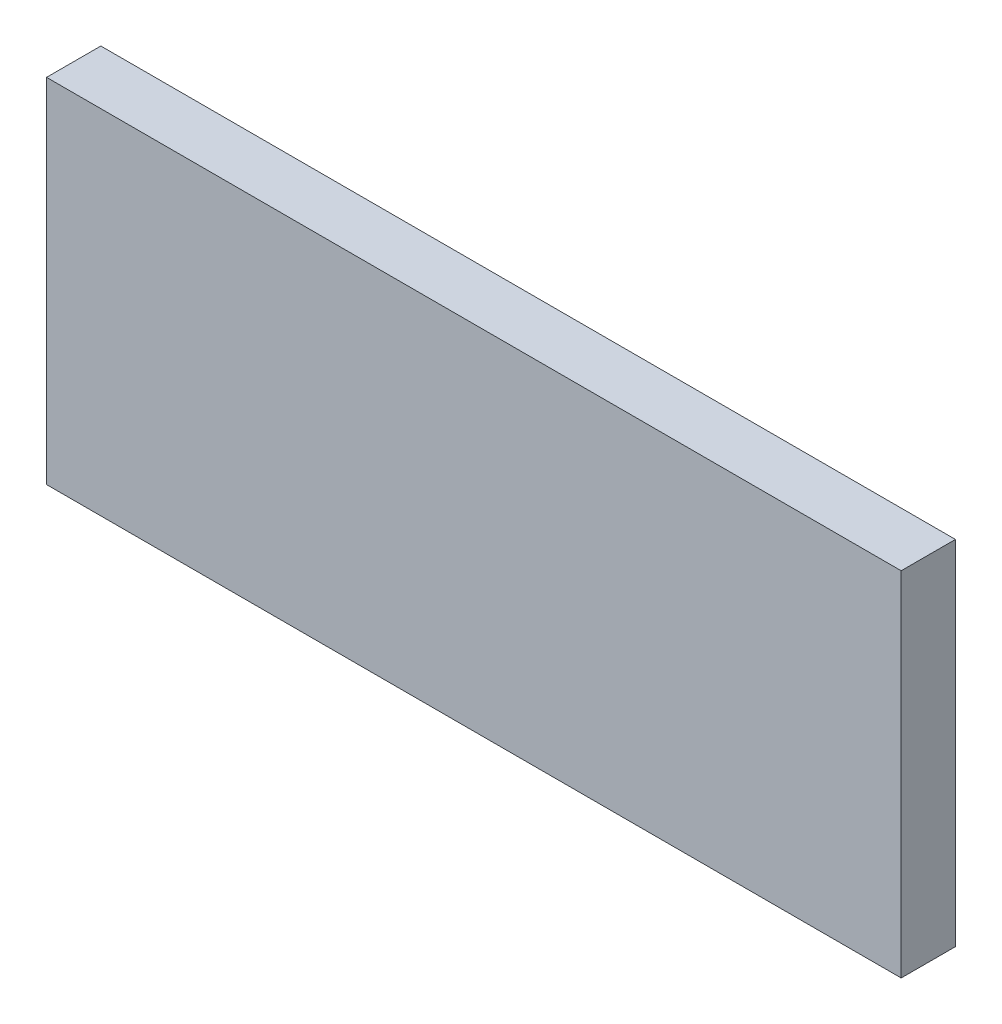
from build123d import *

# Parameters (mm, degrees)
SKETCH1_W           = 63
SKETCH1_H           = 26
BOSS_EXTRUDE1_DEPTH = 4


with BuildPart() as part:
    # Sketch1 → Boss-Extrude1 (new body)
    with BuildSketch(Plane.XY):
        with Locations((-2.100853382, -3.649122807)):
            Rectangle(SKETCH1_W, SKETCH1_H)
    extrude(amount=BOSS_EXTRUDE1_DEPTH)


solid = part.part
